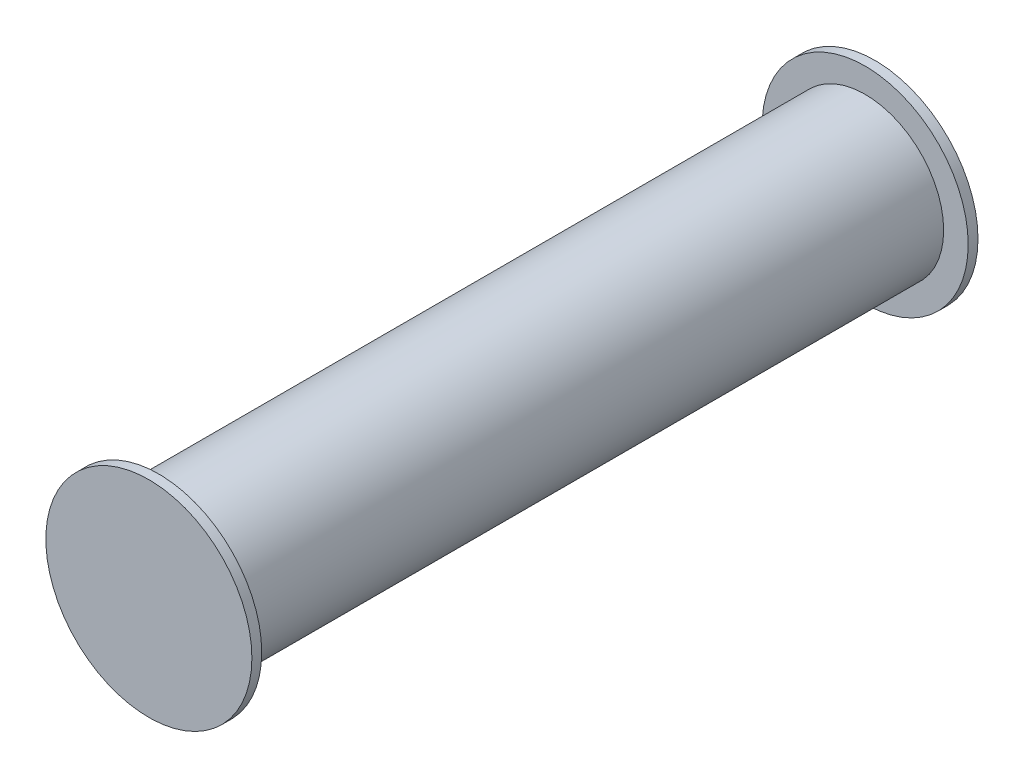
from build123d import *

# Parameters (mm, degrees)
SKETCH1_R           = 50.8
BOSS_EXTRUDE1_DEPTH = 457.2
SKETCH2_R           = 41.275
CUT_EXTRUDE1_DEPTH  = 457.2
SKETCH3_R           = 66.675
BOSS_EXTRUDE2_DEPTH = 6.35


with BuildPart() as part:
    # Sketch1 → Boss-Extrude1 (new body)
    with BuildSketch(Plane.XY):
        Circle(SKETCH1_R)
    extrude(amount=BOSS_EXTRUDE1_DEPTH)

    # Sketch2 → Cut-Extrude1 (cut)
    with BuildSketch(Plane.XY.offset(457.2)):
        Circle(SKETCH2_R)
    extrude(amount=-CUT_EXTRUDE1_DEPTH, mode=Mode.SUBTRACT)

    # Sketch3 → Boss-Extrude2 (add)
    with BuildSketch(Plane.XY.offset(457.2)):
        Circle(SKETCH3_R)
    boss_extrude2 = extrude(amount=BOSS_EXTRUDE2_DEPTH)

    # Mirror1: Boss-Extrude2 across plane
    add(boss_extrude2.mirror(Plane.XY.offset(228.6)))


solid = part.part
